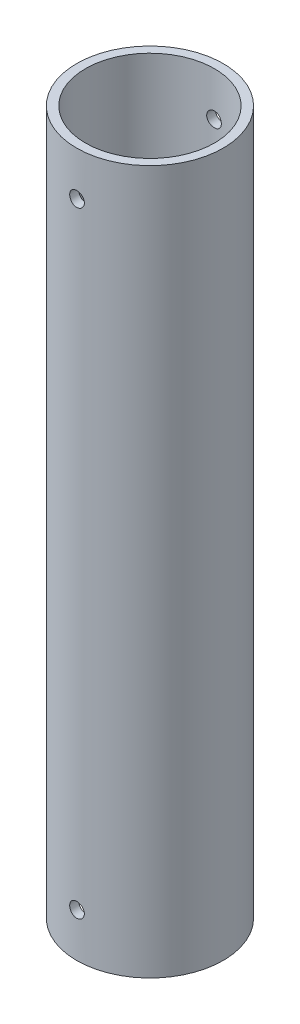
from build123d import *

# Parameters (mm, degrees)
ESBO_O1_R                = 25
ESBO_O1_R_2              = 22
RESSALTO_EXTRUS_O1_DEPTH = 240
ESBO_O2_R                = 2.5
CORTE_EXTRUS_O1_DEPTH    = 243.590189414


with BuildPart() as part:
    # Esboço1 → Ressalto-extrusão1 (new body)
    with BuildSketch(Plane(origin=(0, 0, 0), x_dir=(1, 0, 0), z_dir=(0, 1, 0))):
        with Locations(Location((0, 0, 0), (0, 0, 270))):
            Circle(ESBO_O1_R)
        with Locations(Location((0, 0, 0), (0, 0, 270))):
            Circle(ESBO_O1_R_2, mode=Mode.SUBTRACT)
    extrude(amount=RESSALTO_EXTRUS_O1_DEPTH)

    # Esboço2 → Corte-extrusão1 (cut, symmetric)
    with BuildSketch(Plane.XY):
        with Locations((0, 15)):
            Circle(ESBO_O2_R)
    corte_extrus_o1 = extrude(amount=CORTE_EXTRUS_O1_DEPTH, both=True, mode=Mode.SUBTRACT)

    # Espelhar1: Corte-extrusão1 across plane
    add(corte_extrus_o1.mirror(Plane(origin=(0, 120, 0), x_dir=(0, 0, 1), z_dir=(0, -1, 0))), mode=Mode.SUBTRACT)


solid = part.part
